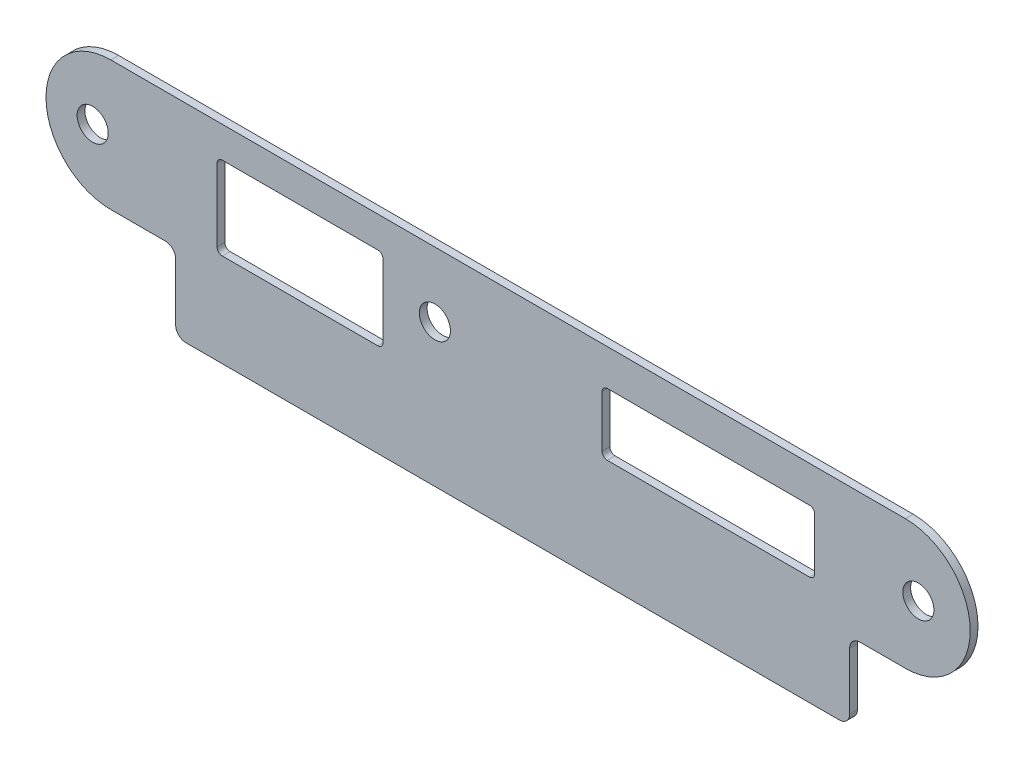
from build123d import *

# Parameters (mm, degrees)
ESQUISSE1_R      = 3
EXTRUSION1_DEPTH = 1.5


with BuildPart() as part:
    # Esquisse1 → Extrusion1 (new body)
    with BuildSketch(Plane.XY):
        with BuildLine():
            Line((-83, -6), (-72.5, -6))
            ThreePointArc((-72.5, -6), (-71.085786438, -6.585786438), (-70.5, -8))
            Line((-70.5, -8), (-70.5, -19))
            ThreePointArc((-70.5, -19), (-69.914213562, -20.414213562), (-68.5, -21))
            Line((-68.5, -21), (57.5, -21))
            ThreePointArc((57.5, -21), (58.914213562, -20.414213562), (59.5, -19))
            Line((59.5, -19), (59.5, -8))
            ThreePointArc((59.5, -8), (60.085786438, -6.585786438), (61.5, -6))
            Line((61.5, -6), (70.25, -6))
            ThreePointArc((70.25, -6), (82.75, 6.5), (70.25, 19))
            Line((70.25, 19), (-83, 19))
            ThreePointArc((-83, 19), (-95.5, 6.5), (-83, -6))
        make_face()
        with Locations((-86.5, 6.5)):
            Circle(ESQUISSE1_R, mode=Mode.SUBTRACT)
        with Locations((-20.5, 6.5)):
            Circle(ESQUISSE1_R, mode=Mode.SUBTRACT)
        with Locations((72.75, 6.5)):
            Circle(ESQUISSE1_R, mode=Mode.SUBTRACT)
        with BuildLine():
            Line((-31.5, 13), (-61.5, 13))
            ThreePointArc((-61.5, 13), (-62.207106781, 12.707106781), (-62.5, 12))
            Line((-62.5, 12), (-62.5, -2))
            ThreePointArc((-62.5, -2), (-62.207106781, -2.707106781), (-61.5, -3))
            Line((-61.5, -3), (-31.5, -3))
            ThreePointArc((-31.5, -3), (-30.792893219, -2.707106781), (-30.5, -2))
            Line((-30.5, -2), (-30.5, 12))
            ThreePointArc((-30.5, 12), (-30.792893219, 12.707106781), (-31.5, 13))
        make_face(mode=Mode.SUBTRACT)
        with BuildLine():
            Line((51.75, 12), (12.75, 12))
            ThreePointArc((12.75, 12), (12.042893219, 11.707106781), (11.75, 11))
            Line((11.75, 11), (11.75, 1))
            ThreePointArc((11.75, 1), (12.042893219, 0.292893219), (12.75, 0))
            Line((12.75, 0), (51.75, 0))
            ThreePointArc((51.75, 0), (52.457106781, 0.292893219), (52.75, 1))
            Line((52.75, 1), (52.75, 11))
            ThreePointArc((52.75, 11), (52.457106781, 11.707106781), (51.75, 12))
        make_face(mode=Mode.SUBTRACT)
    extrude(amount=EXTRUSION1_DEPTH)


solid = part.part
